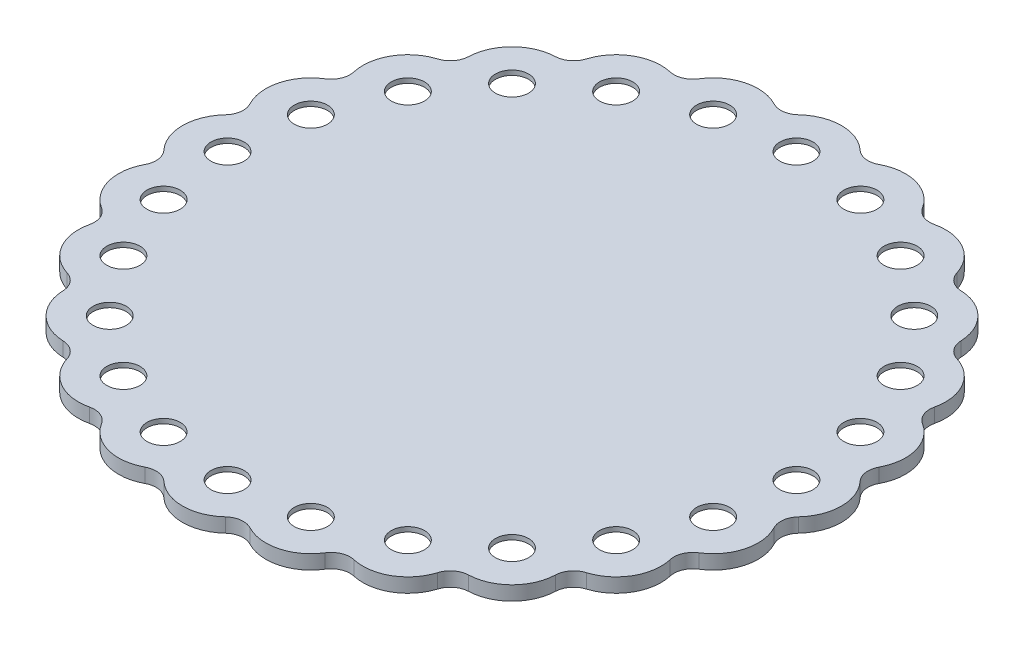
from build123d import *

# Parameters (mm, degrees)
EXTRUDE_2_DEPTH     = 3
SKETCH_1_R          = 3.5
CUT_EXTRUDE_2_DEPTH = 4
SKETCH_2_R          = 6.5
CUT_EXTRUDE_4_DEPTH = 2


with BuildPart() as part:
    # Эскиз3 → Бобышка-Вытянуть2 (new body)
    with BuildSketch(Plane(origin=(0, 0, 0), x_dir=(1, 0, 0), z_dir=(0, 1, 0))):
        with BuildLine():
            ThreePointArc((-6.4739783, 66.952525078), (0, 69.5), (6.4739783, 66.952525078))
            ThreePointArc((6.4739783, 66.952525078), (8.677759132, 65.914124613), (11.075205769, 66.34676199))
            ThreePointArc((11.075205769, 66.34676199), (17.987923635, 67.131844927), (23.581971447, 62.995584227))
            ThreePointArc((23.581971447, 62.995584227), (25.441902451, 61.422185949), (27.869632868, 61.219576716))
            ThreePointArc((27.869632868, 61.219576716), (34.75, 60.188765563), (39.082892211, 54.745598415))
            ThreePointArc((39.082892211, 54.745598415), (40.472222163, 52.744426818), (42.764790543, 51.920378458))
            ThreePointArc((42.764790543, 51.920378458), (49.143921292, 49.143921292), (51.920378458, 42.764790543))
            ThreePointArc((51.920378458, 42.764790543), (52.744426818, 40.472222163), (54.745598415, 39.082892211))
            ThreePointArc((54.745598415, 39.082892211), (60.188765563, 34.75), (61.219576716, 27.869632868))
            ThreePointArc((61.219576716, 27.869632868), (61.422185949, 25.441902451), (62.995584227, 23.581971447))
            ThreePointArc((62.995584227, 23.581971447), (67.131844927, 17.987923635), (66.34676199, 11.075205769))
            ThreePointArc((66.34676199, 11.075205769), (65.914124613, 8.677759132), (66.952525078, 6.4739783))
            ThreePointArc((66.952525078, 6.4739783), (69.5, 0), (66.952525078, -6.4739783))
            ThreePointArc((66.952525078, -6.4739783), (65.914124613, -8.677759132), (66.34676199, -11.075205769))
            ThreePointArc((66.34676199, -11.075205769), (67.131844927, -17.987923635), (62.995584227, -23.581971447))
            ThreePointArc((62.995584227, -23.581971447), (61.422185949, -25.441902451), (61.219576716, -27.869632868))
            ThreePointArc((61.219576716, -27.869632868), (60.188765563, -34.75), (54.745598415, -39.082892211))
            ThreePointArc((54.745598415, -39.082892211), (52.744426818, -40.472222163), (51.920378458, -42.764790543))
            ThreePointArc((51.920378458, -42.764790543), (49.143921292, -49.143921292), (42.764790543, -51.920378458))
            ThreePointArc((42.764790543, -51.920378458), (40.472222163, -52.744426818), (39.082892211, -54.745598415))
            ThreePointArc((39.082892211, -54.745598415), (34.75, -60.188765563), (27.869632868, -61.219576716))
            ThreePointArc((27.869632868, -61.219576716), (25.441902451, -61.422185949), (23.581971447, -62.995584227))
            ThreePointArc((23.581971447, -62.995584227), (17.987923635, -67.131844927), (11.075205769, -66.34676199))
            ThreePointArc((11.075205769, -66.34676199), (8.677759132, -65.914124613), (6.4739783, -66.952525078))
            ThreePointArc((6.4739783, -66.952525078), (0, -69.5), (-6.4739783, -66.952525078))
            ThreePointArc((-6.4739783, -66.952525078), (-8.677759132, -65.914124613), (-11.075205769, -66.34676199))
            ThreePointArc((-11.075205769, -66.34676199), (-17.987923635, -67.131844927), (-23.581971447, -62.995584227))
            ThreePointArc((-23.581971447, -62.995584227), (-25.441902451, -61.422185949), (-27.869632868, -61.219576716))
            ThreePointArc((-27.869632868, -61.219576716), (-34.75, -60.188765563), (-39.082892211, -54.745598415))
            ThreePointArc((-39.082892211, -54.745598415), (-40.472222163, -52.744426818), (-42.764790543, -51.920378458))
            ThreePointArc((-42.764790543, -51.920378458), (-49.143921292, -49.143921292), (-51.920378458, -42.764790543))
            ThreePointArc((-51.920378458, -42.764790543), (-52.744426818, -40.472222163), (-54.745598415, -39.082892211))
            ThreePointArc((-54.745598415, -39.082892211), (-60.188765563, -34.75), (-61.219576716, -27.869632868))
            ThreePointArc((-61.219576716, -27.869632868), (-61.422185949, -25.441902451), (-62.995584227, -23.581971447))
            ThreePointArc((-62.995584227, -23.581971447), (-67.131844927, -17.987923635), (-66.34676199, -11.075205769))
            ThreePointArc((-66.34676199, -11.075205769), (-65.914124613, -8.677759132), (-66.952525078, -6.4739783))
            ThreePointArc((-66.952525078, -6.4739783), (-69.5, 0), (-66.952525078, 6.4739783))
            ThreePointArc((-66.952525078, 6.4739783), (-65.914124613, 8.677759132), (-66.34676199, 11.075205769))
            ThreePointArc((-66.34676199, 11.075205769), (-67.131844927, 17.987923635), (-62.995584227, 23.581971447))
            ThreePointArc((-62.995584227, 23.581971447), (-61.422185949, 25.441902451), (-61.219576716, 27.869632868))
            ThreePointArc((-61.219576716, 27.869632868), (-60.188765563, 34.75), (-54.745598415, 39.082892211))
            ThreePointArc((-54.745598415, 39.082892211), (-52.744426818, 40.472222163), (-51.920378458, 42.764790543))
            ThreePointArc((-51.920378458, 42.764790543), (-49.143921292, 49.143921292), (-42.764790543, 51.920378458))
            ThreePointArc((-42.764790543, 51.920378458), (-40.472222163, 52.744426818), (-39.082892211, 54.745598415))
            ThreePointArc((-39.082892211, 54.745598415), (-34.75, 60.188765563), (-27.869632868, 61.219576716))
            ThreePointArc((-27.869632868, 61.219576716), (-25.441902451, 61.422185949), (-23.581971447, 62.995584227))
            ThreePointArc((-23.581971447, 62.995584227), (-17.987923635, 67.131844927), (-11.075205769, 66.34676199))
            ThreePointArc((-11.075205769, 66.34676199), (-8.677759132, 65.914124613), (-6.4739783, 66.952525078))
        make_face()
    extrude(amount=EXTRUDE_2_DEPTH)

    # Эскиз1 → Вырез-Вытянуть2 (cut, through all)
    with BuildSketch(Plane(origin=(0, 0, 0), x_dir=(1, 0, 0), z_dir=(0, 1, 0))):
        with Locations((0, 60)):
            Circle(SKETCH_1_R)
        with Locations((15.529142706, 57.955549577)):
            Circle(SKETCH_1_R)
        with Locations((30, 51.961524227)):
            Circle(SKETCH_1_R)
        with Locations((42.426406871, 42.426406871)):
            Circle(SKETCH_1_R)
        with Locations((51.961524227, 30)):
            Circle(SKETCH_1_R)
        with Locations((57.955549577, 15.529142706)):
            Circle(SKETCH_1_R)
        with Locations((60, 0)):
            Circle(SKETCH_1_R)
        with Locations((57.955549577, -15.529142706)):
            Circle(SKETCH_1_R)
        with Locations((51.961524227, -30)):
            Circle(SKETCH_1_R)
        with Locations((42.426406871, -42.426406871)):
            Circle(SKETCH_1_R)
        with Locations((30, -51.961524227)):
            Circle(SKETCH_1_R)
        with Locations((15.529142706, -57.955549577)):
            Circle(SKETCH_1_R)
        with Locations((0, -60)):
            Circle(SKETCH_1_R)
        with Locations((-15.529142706, -57.955549577)):
            Circle(SKETCH_1_R)
        with Locations((-30, -51.961524227)):
            Circle(SKETCH_1_R)
        with Locations((-42.426406871, -42.426406871)):
            Circle(SKETCH_1_R)
        with Locations((-51.961524227, -30)):
            Circle(SKETCH_1_R)
        with Locations((-57.955549577, -15.529142706)):
            Circle(SKETCH_1_R)
        with Locations((-60, 0)):
            Circle(SKETCH_1_R)
        with Locations((-57.955549577, 15.529142706)):
            Circle(SKETCH_1_R)
        with Locations((-51.961524227, 30)):
            Circle(SKETCH_1_R)
        with Locations((-42.426406871, 42.426406871)):
            Circle(SKETCH_1_R)
        with Locations((-30, 51.961524227)):
            Circle(SKETCH_1_R)
        with Locations((-15.529142706, 57.955549577)):
            Circle(SKETCH_1_R)
    extrude(amount=CUT_EXTRUDE_2_DEPTH, mode=Mode.SUBTRACT)

    # Эскиз2 → Вырез-Вытянуть4 (cut)
    with BuildSketch(Plane(origin=(0, 0, 0), x_dir=(1, 0, 0), z_dir=(0, 1, 0))):
        with Locations((0, 60)):
            Circle(SKETCH_2_R)
        with Locations((15.529142706, 57.955549577)):
            Circle(SKETCH_2_R)
        with Locations((30, 51.961524227)):
            Circle(SKETCH_2_R)
        with Locations((42.426406871, 42.426406871)):
            Circle(SKETCH_2_R)
        with Locations((51.961524227, 30)):
            Circle(SKETCH_2_R)
        with Locations((57.955549577, 15.529142706)):
            Circle(SKETCH_2_R)
        with Locations((60, 0)):
            Circle(SKETCH_2_R)
        with Locations((57.955549577, -15.529142706)):
            Circle(SKETCH_2_R)
        with Locations((51.961524227, -30)):
            Circle(SKETCH_2_R)
        with Locations((42.426406871, -42.426406871)):
            Circle(SKETCH_2_R)
        with Locations((30, -51.961524227)):
            Circle(SKETCH_2_R)
        with Locations((15.529142706, -57.955549577)):
            Circle(SKETCH_2_R)
        with Locations((0, -60)):
            Circle(SKETCH_2_R)
        with Locations((-15.529142706, -57.955549577)):
            Circle(SKETCH_2_R)
        with Locations((-30, -51.961524227)):
            Circle(SKETCH_2_R)
        with Locations((-42.426406871, -42.426406871)):
            Circle(SKETCH_2_R)
        with Locations((-51.961524227, -30)):
            Circle(SKETCH_2_R)
        with Locations((-57.955549577, -15.529142706)):
            Circle(SKETCH_2_R)
        with Locations((-60, 0)):
            Circle(SKETCH_2_R)
        with Locations((-57.955549577, 15.529142706)):
            Circle(SKETCH_2_R)
        with Locations((-51.961524227, 30)):
            Circle(SKETCH_2_R)
        with Locations((-42.426406871, 42.426406871)):
            Circle(SKETCH_2_R)
        with Locations((-30, 51.961524227)):
            Circle(SKETCH_2_R)
        with Locations((-15.529142706, 57.955549577)):
            Circle(SKETCH_2_R)
    extrude(amount=CUT_EXTRUDE_4_DEPTH, mode=Mode.SUBTRACT)


solid = part.part
